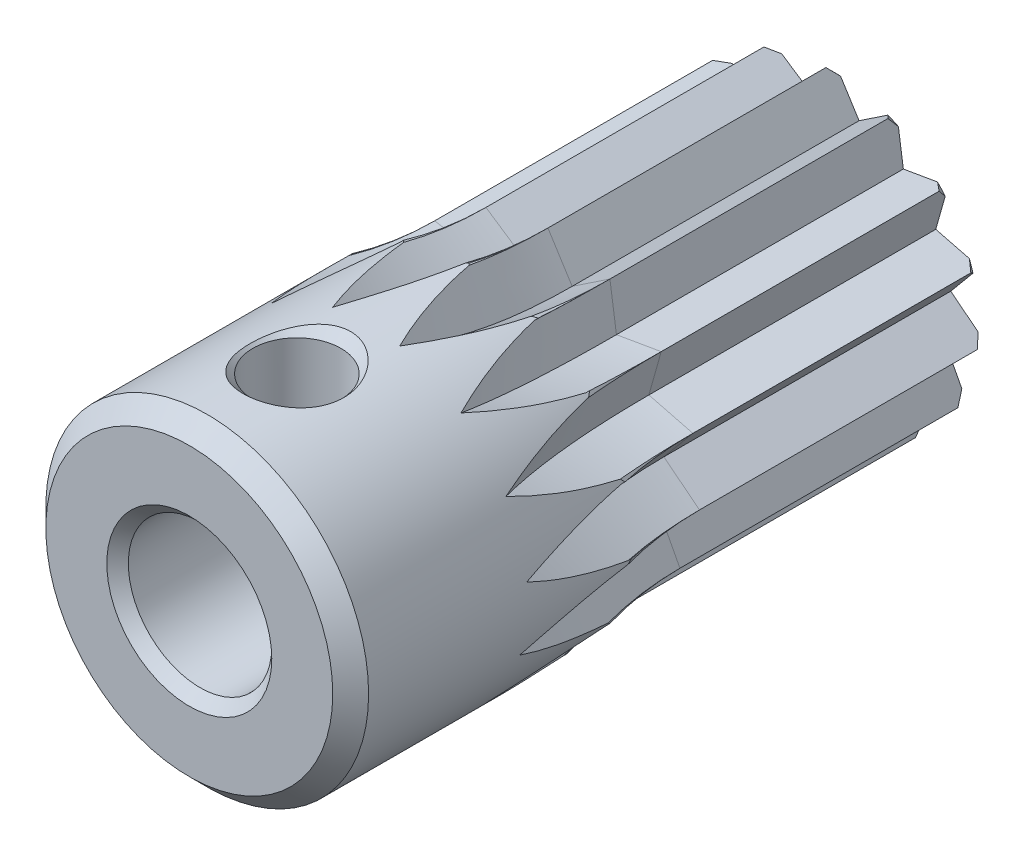
from build123d import *

# Parameters (mm, degrees)
SKETCH2_R          = 8.5
CUT_EXTRUDE1_DEPTH = 8


with BuildPart() as part:
    # Sketch1 → Revolve1 (revolve)
    with BuildSketch(Plane(origin=(0, 0, 0), x_dir=(0, 0, -1), z_dir=(1, 0, 0))):
        Polygon((-18, 2.3), (-17.7, 2), (-0.3, 2), (0, 2.3), (0, 4), (-0.5, 4.5), (-17.5, 4.5), (-18, 4), align=None)
    revolve(axis=Axis((0, 0, 0), (0, 0, 1)))

    # Sketch2 → Cut-Extrude1 (cut)
    with BuildSketch(Plane.XY.offset(8)):
        Circle(SKETCH2_R)
        Polygon((-4.226718055, -0.444245969), (-3.090933678, -1.004305232), (-3.680607966, -2.125), (-2.415220683, -2.174674471), (-2.498087322, -3.438322226), (-1.32189409, -2.969022737), (-0.883624686, -4.157127303), (0, -3.25), (0.883624686, -4.157127303), (1.32189409, -2.969022737), (2.498087322, -3.438322226), (2.415220683, -2.174674471), (3.680607966, -2.125), (3.090933678, -1.004305232), (4.226718055, -0.444245969), (3.23219616, 0.339717506), (4.041990194, 1.313322226), (2.814582562, 1.625), (3.158365508, 2.843805077), (1.91030207, 2.629305232), (1.728630733, 3.882568195), (0.675712995, 3.178979702), (0, 4.25), (-0.675712995, 3.178979702), (-1.728630733, 3.882568195), (-1.91030207, 2.629305232), (-3.158365508, 2.843805077), (-2.814582562, 1.625), (-4.041990194, 1.313322226), (-3.23219616, 0.339717506), align=None, mode=Mode.SUBTRACT)
    extrude(amount=-CUT_EXTRUDE1_DEPTH, mode=Mode.SUBTRACT)

    # Sketch3 → Cut-Revolve1 (revolve, cut)
    with BuildSketch(Plane.XY.offset(8)):
        Polygon((-2.079116908, 14.031476007), (0, 4.25), (-0.675712995, 3.178979702), (-1.728630733, 3.882568195), (-3.807747641, 13.664044202), align=None)
    revolve(axis=Axis((-3.807747641, 13.664044202, 8), (0.978147601, 0.207911691, 0)), mode=Mode.SUBTRACT)

    # Sketch4 → Cut-Revolve2 (revolve, cut)
    with BuildSketch(Plane.XY.offset(8)):
        Polygon((3.807747641, 13.664044202), (1.728630733, 3.882568195), (0.675712995, 3.178979702), (0, 4.25), (2.079116908, 14.031476007), align=None)
    revolve(axis=Axis((2.079116908, 14.031476007, 8), (0.978147601, -0.207911691, 0)), mode=Mode.SUBTRACT)

    # Sketch5 → Cut-Revolve3 (revolve, cut)
    with BuildSketch(Plane.XY.offset(8)):
        Polygon((9.036218031, 10.933975021), (3.158365508, 2.843805077), (1.91030207, 2.629305232), (1.728630733, 3.882568195), (7.606483256, 11.972738139), align=None)
    revolve(axis=Axis((7.606483256, 11.972738139, 8), (0.809016994, -0.587785252, 0)), mode=Mode.SUBTRACT)

    # Sketch6 → Cut-Revolve4 (revolve, cut)
    with BuildSketch(Plane.XY.offset(8)):
        Polygon((12.702244232, 6.313322226), (4.041990194, 1.313322226), (2.814582562, 1.625), (3.158365508, 2.843805077), (11.818619546, 7.843805077), align=None)
    revolve(axis=Axis((11.818619546, 7.843805077, 8), (0.5, -0.866025404, 0)), mode=Mode.SUBTRACT)

    # Sketch7 → Cut-Revolve5 (revolve, cut)
    with BuildSketch(Plane.XY.offset(8)):
        Polygon((14.171937009, 0.601038664), (4.226718055, -0.444245969), (3.23219616, 0.339717506), (4.041990194, 1.313322226), (13.987209148, 2.358606859), align=None)
    revolve(axis=Axis((13.987209148, 2.358606859, 8), (0.104528463, -0.994521895, 0)), mode=Mode.SUBTRACT)

    # Sketch8 → Cut-Revolve6 (revolve, cut)
    with BuildSketch(Plane.XY.offset(8)):
        Polygon((13.191173129, -5.215169944), (3.680607966, -2.125), (3.090933678, -1.004305232), (4.226718055, -0.444245969), (13.737283218, -3.534415913), align=None)
    revolve(axis=Axis((13.737283218, -3.534415913, 8), (-0.309016994, -0.951056516, 0)), mode=Mode.SUBTRACT)

    # Sketch9 → Cut-Revolve7 (revolve, cut)
    with BuildSketch(Plane.XY.offset(8)):
        Polygon((9.929535577, -10.12962829), (2.498087322, -3.438322226), (2.415220683, -2.174674471), (3.680607966, -2.125), (11.112056221, -8.816306064), align=None)
    revolve(axis=Axis((11.112056221, -8.816306064, 8), (-0.669130606, -0.743144825, 0)), mode=Mode.SUBTRACT)

    # Sketch10 → Cut-Revolve8 (revolve, cut)
    with BuildSketch(Plane.XY.offset(8)):
        Polygon((4.950991117, -13.29258188), (0.883624686, -4.157127303), (1.32189409, -2.969022737), (2.498087322, -3.438322226), (6.565453753, -12.573776803), align=None)
    revolve(axis=Axis((6.565453753, -12.573776803, 8), (-0.913545458, -0.406736643, 0)), mode=Mode.SUBTRACT)

    # Sketch11 → Cut-Revolve9 (revolve, cut)
    with BuildSketch(Plane.XY.offset(8)):
        Polygon((-0.883624686, -14.157127303), (-0.883624686, -4.157127303), (0, -3.25), (0.883624686, -4.157127303), (0.883624686, -14.157127303), align=None)
    revolve(axis=Axis((0.883624686, -14.157127303, 8), (-1, 0, 0)), mode=Mode.SUBTRACT)

    # Sketch12 → Cut-Revolve10 (revolve, cut)
    with BuildSketch(Plane.XY.offset(8)):
        Polygon((-6.565453753, -12.573776803), (-2.498087322, -3.438322226), (-1.32189409, -2.969022737), (-0.883624686, -4.157127303), (-4.950991117, -13.29258188), align=None)
    revolve(axis=Axis((-4.950991117, -13.29258188, 8), (-0.913545458, 0.406736643, 0)), mode=Mode.SUBTRACT)

    # Sketch13 → Cut-Revolve11 (revolve, cut)
    with BuildSketch(Plane.XY.offset(8)):
        Polygon((-11.112056221, -8.816306064), (-3.680607966, -2.125), (-2.415220683, -2.174674471), (-2.498087322, -3.438322226), (-9.929535577, -10.12962829), align=None)
    revolve(axis=Axis((-9.929535577, -10.12962829, 8), (-0.669130606, 0.743144825, 0)), mode=Mode.SUBTRACT)

    # Sketch14 → Cut-Revolve12 (revolve, cut)
    with BuildSketch(Plane.XY.offset(8)):
        Polygon((-13.737283218, -3.534415913), (-4.226718055, -0.444245969), (-3.090933678, -1.004305232), (-3.680607966, -2.125), (-13.191173129, -5.215169944), align=None)
    revolve(axis=Axis((-13.191173129, -5.215169944, 8), (-0.309016994, 0.951056516, 0)), mode=Mode.SUBTRACT)

    # Sketch15 → Cut-Revolve13 (revolve, cut)
    with BuildSketch(Plane.XY.offset(8)):
        Polygon((-13.987209148, 2.358606859), (-4.041990194, 1.313322226), (-3.23219616, 0.339717506), (-4.226718055, -0.444245969), (-14.171937009, 0.601038664), align=None)
    revolve(axis=Axis((-14.171937009, 0.601038664, 8), (0.104528463, 0.994521895, 0)), mode=Mode.SUBTRACT)

    # Sketch16 → Cut-Revolve14 (revolve, cut)
    with BuildSketch(Plane.XY.offset(8)):
        Polygon((-11.818619546, 7.843805077), (-3.158365508, 2.843805077), (-2.814582562, 1.625), (-4.041990194, 1.313322226), (-12.702244232, 6.313322226), align=None)
    revolve(axis=Axis((-12.702244232, 6.313322226, 8), (0.5, 0.866025404, 0)), mode=Mode.SUBTRACT)

    # Sketch17 → Cut-Revolve15 (revolve, cut)
    with BuildSketch(Plane.XY.offset(8)):
        Polygon((-7.606483256, 11.972738139), (-1.728630733, 3.882568195), (-1.91030207, 2.629305232), (-3.158365508, 2.843805077), (-9.036218031, 10.933975021), align=None)
    revolve(axis=Axis((-9.036218031, 10.933975021, 8), (0.809016994, 0.587785252, 0)), mode=Mode.SUBTRACT)

    # Sketch18 → Cut-Revolve16 (revolve, cut)
    with BuildSketch(Plane.XY.offset(8)):
        Polygon((-1.883487388, 14.073058346), (0.19562952, 4.291582338), (0, 4.25), (-0.675712995, 3.178979702), (-1.728630733, 3.882568195), (-1.924260253, 3.840985857), (-4.003377161, 13.622461864), align=None)
    revolve(axis=Axis((-4.003377161, 13.622461864, 8), (0.978147601, 0.207911691, 0)), mode=Mode.SUBTRACT)

    # Sketch19 → Cut-Revolve17 (revolve, cut)
    with BuildSketch(Plane.XY.offset(8)):
        Polygon((4.003377161, 13.622461864), (1.924260253, 3.840985857), (1.728630733, 3.882568195), (0.675712995, 3.178979702), (0, 4.25), (-0.19562952, 4.291582338), (1.883487388, 14.073058346), align=None)
    revolve(axis=Axis((1.883487388, 14.073058346, 8), (0.978147601, -0.207911691, 0)), mode=Mode.SUBTRACT)

    # Sketch20 → Cut-Revolve18 (revolve, cut)
    with BuildSketch(Plane.XY.offset(8)):
        Polygon((12.802244232, 6.140117145), (4.141990194, 1.140117145), (4.041990194, 1.313322226), (2.814582562, 1.625), (3.158365508, 2.843805077), (3.058365508, 3.017010158), (11.718619546, 8.017010158), align=None)
    revolve(axis=Axis((11.718619546, 8.017010158, 8), (0.5, -0.866025404, 0)), mode=Mode.SUBTRACT)

    # Sketch21 → Cut-Revolve19 (revolve, cut)
    with BuildSketch(Plane.XY.offset(8)):
        Polygon((13.12936973, -5.405381247), (3.618804567, -2.315211303), (3.680607966, -2.125), (3.090933678, -1.004305232), (4.226718055, -0.444245969), (4.288521454, -0.254034666), (13.799086617, -3.344204609), align=None)
    revolve(axis=Axis((13.799086617, -3.344204609, 8), (-0.309016994, -0.951056516, 0)), mode=Mode.SUBTRACT)

    # Sketch22 → Cut-Revolve20 (revolve, cut)
    with BuildSketch(Plane.XY.offset(8)):
        Polygon((4.768282025, -13.373929208), (0.700915594, -4.238474632), (0.883624686, -4.157127303), (1.32189409, -2.969022737), (2.498087322, -3.438322226), (2.680796414, -3.356974897), (6.748162845, -12.492429474), align=None)
    revolve(axis=Axis((6.748162845, -12.492429474, 8), (-0.913545458, -0.406736643, 0)), mode=Mode.SUBTRACT)

    # Sketch23 → Cut-Revolve21 (revolve, cut)
    with BuildSketch(Plane.XY.offset(8)):
        Polygon((-6.748162845, -12.492429474), (-2.680796414, -3.356974897), (-2.498087322, -3.438322226), (-1.32189409, -2.969022737), (-0.883624686, -4.157127303), (-0.700915594, -4.238474632), (-4.768282025, -13.373929208), align=None)
    revolve(axis=Axis((-4.768282025, -13.373929208, 8), (-0.913545458, 0.406736643, 0)), mode=Mode.SUBTRACT)

    # Sketch24 → Cut-Revolve22 (revolve, cut)
    with BuildSketch(Plane.XY.offset(8)):
        Polygon((-13.799086617, -3.344204609), (-4.288521454, -0.254034666), (-4.226718055, -0.444245969), (-3.090933678, -1.004305232), (-3.680607966, -2.125), (-3.618804567, -2.315211303), (-13.12936973, -5.405381247), align=None)
    revolve(axis=Axis((-13.12936973, -5.405381247, 8), (-0.309016994, 0.951056516, 0)), mode=Mode.SUBTRACT)

    # Sketch25 → Cut-Revolve23 (revolve, cut)
    with BuildSketch(Plane.XY.offset(8)):
        Polygon((-11.718619546, 8.017010158), (-3.058365508, 3.017010158), (-3.158365508, 2.843805077), (-2.814582562, 1.625), (-4.041990194, 1.313322226), (-4.141990194, 1.140117145), (-12.802244232, 6.140117145), align=None)
    revolve(axis=Axis((-12.802244232, 6.140117145, 8), (0.5, 0.866025404, 0)), mode=Mode.SUBTRACT)

    # Sketch26 → Cut-Revolve24 (revolve, cut)
    with BuildSketch(Plane.XY.offset(15)):
        Polygon((0, 0), (-1.5, 0), (-1.5, 2), (-1.2295, 2.2705), (-1.2295, 4.2295), (-1.5, 4.5), (-1.5, 8.5), (0, 8.5), align=None)
    revolve(axis=Axis((0, 8.5, 15), (0, -1, 0)), mode=Mode.SUBTRACT)


solid = part.part
